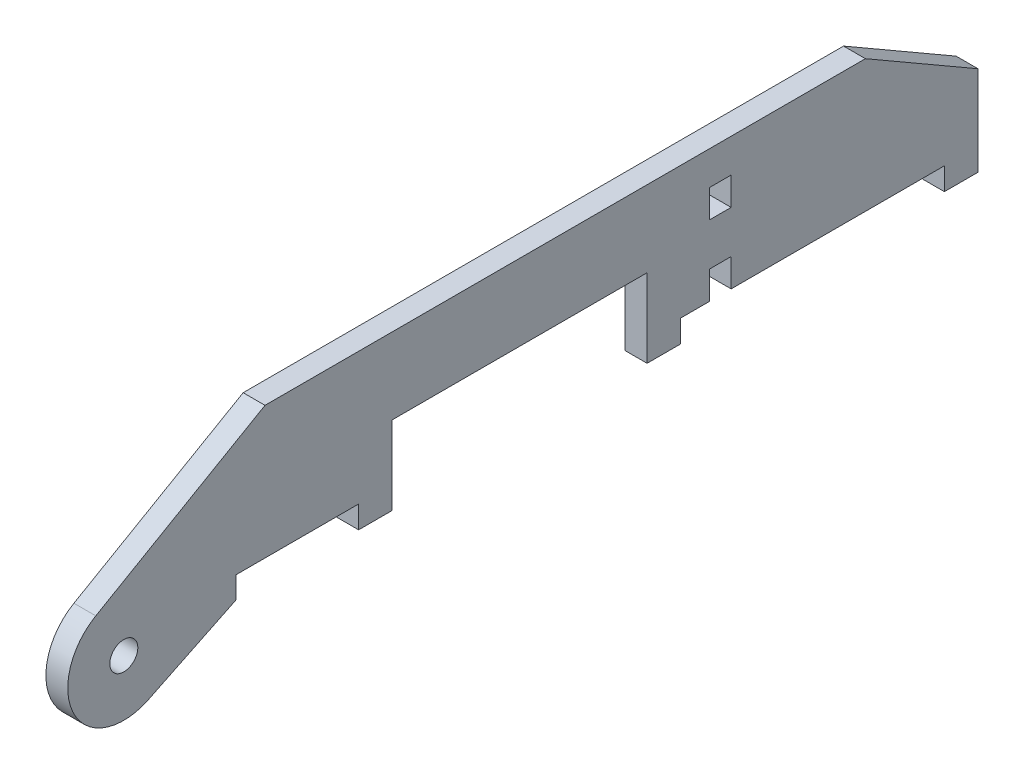
from build123d import *

# Parameters (mm, degrees)
SKETCH1_R           = 3.175
SKETCH1_W           = 4.953
SKETCH1_H           = 6.35
BOSS_EXTRUDE1_DEPTH = 2.4765


with BuildPart() as part:
    # Sketch1 → Boss-Extrude1 (new, symmetric)
    with BuildSketch(Plane(origin=(0, 0, 0), x_dir=(0, 0, -1), z_dir=(1, 0, 0))):
        with BuildLine():
            Line((-94.642365809, 54.483), (-122.457292876, 54.483))
            Line((-122.457292876, 54.483), (-122.457292876, 49.53))
            Line((-122.457292876, 49.53), (-142.309833129, 39.889958968))
            ThreePointArc((-142.309833129, 39.889958968), (-159.075906045, 45.361766519), (-154.207292876, 62.312827982))
            Line((-154.207292876, 62.312827982), (-115.855925951, 84.455))
            Line((-115.855925951, 84.455), (20.203427503, 84.455))
            Line((20.203427503, 84.455), (45.72, 69.723))
            Line((45.72, 69.723), (45.72, 49.403))
            Line((45.72, 49.403), (38.1, 49.403))
            Line((38.1, 49.403), (38.1, 54.483))
            Line((38.1, 54.483), (-10.2235, 54.483))
            Line((-10.2235, 54.483), (-10.2235, 60.833))
            Line((-10.2235, 60.833), (-15.1765, 60.833))
            Line((-15.1765, 60.833), (-15.1765, 54.483))
            Line((-15.1765, 54.483), (-21.651856626, 54.483))
            Line((-21.651856626, 54.483), (-21.651856626, 49.403))
            Line((-21.651856626, 49.403), (-29.271856626, 49.403))
            Line((-29.271856626, 49.403), (-29.271856626, 67.183))
            Line((-29.271856626, 67.183), (-87.022365809, 67.183))
            Line((-87.022365809, 67.183), (-87.022365809, 49.403))
            Line((-87.022365809, 49.403), (-94.642365809, 49.403))
            Line((-94.642365809, 49.403), (-94.642365809, 54.483))
        make_face()
        with Locations((-147.857292876, 51.314305354)):
            Circle(SKETCH1_R, mode=Mode.SUBTRACT)
        with Locations((-12.7, 73.66)):
            Rectangle(SKETCH1_W, SKETCH1_H, mode=Mode.SUBTRACT)
    extrude(amount=BOSS_EXTRUDE1_DEPTH, both=True)


solid = part.part
